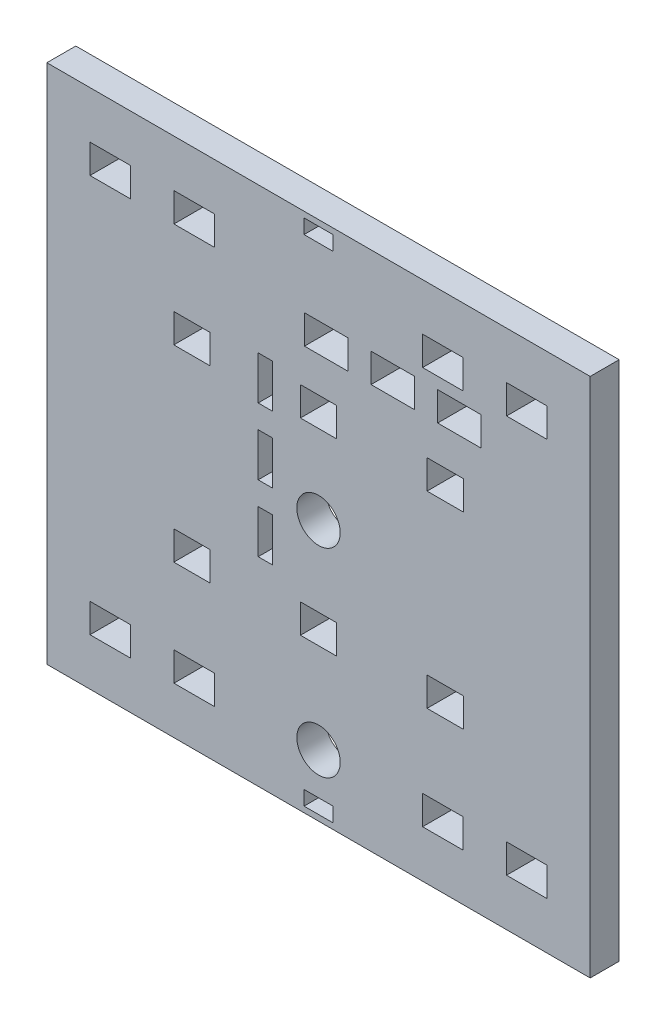
from build123d import *

# Parameters (mm, degrees)
SKETCH1_W           = 187.7087417
SKETCH1_H           = 180
SKETCH1_W_2         = 14
SKETCH1_H_2         = 10
SKETCH1_W_3         = 12.5
SKETCH1_W_4         = 5
SKETCH1_H_3         = 15
SKETCH1_W_5         = 10
SKETCH1_H_4         = 5
SKETCH1_R           = 7.5
SKETCH1_W_6         = 15
BOSS_EXTRUDE1_DEPTH = 10


with BuildPart() as part:
    # Sketch1 → Boss-Extrude1 (new body)
    with BuildSketch(Plane.XY):
        Rectangle(SKETCH1_W, SKETCH1_H)
        with Locations((-71.95437085, -68.7)):
            Rectangle(SKETCH1_W_2, SKETCH1_H_2, mode=Mode.SUBTRACT)
        with Locations((-42.95437085, -68.7)):
            Rectangle(SKETCH1_W_2, SKETCH1_H_2, mode=Mode.SUBTRACT)
        with Locations((-43.75, -32.5)):
            Rectangle(SKETCH1_W_3, SKETCH1_H_2, mode=Mode.SUBTRACT)
        with Locations((-18.35, -13.8)):
            Rectangle(SKETCH1_W_4, SKETCH1_H_3, mode=Mode.SUBTRACT)
        with Locations((0, -85.5)):
            Rectangle(SKETCH1_W_5, SKETCH1_H_4, mode=Mode.SUBTRACT)
        with Locations((0, -68.7)):
            Circle(SKETCH1_R, mode=Mode.SUBTRACT)
        with Locations((42.95437085, -68.7)):
            Rectangle(SKETCH1_W_2, SKETCH1_H_2, mode=Mode.SUBTRACT)
        with Locations((71.95437085, -68.7)):
            Rectangle(SKETCH1_W_2, SKETCH1_H_2, mode=Mode.SUBTRACT)
        with Locations((0, -32.5)):
            Rectangle(SKETCH1_W_3, SKETCH1_H_2, mode=Mode.SUBTRACT)
        with Locations((43.75, -32.5)):
            Rectangle(SKETCH1_W_3, SKETCH1_H_2, mode=Mode.SUBTRACT)
        Circle(SKETCH1_R, mode=Mode.SUBTRACT)
        with Locations((-18.35, 9.2)):
            Rectangle(SKETCH1_W_4, SKETCH1_H_3, mode=Mode.SUBTRACT)
        with Locations((-43.75, 32.5)):
            Rectangle(SKETCH1_W_3, SKETCH1_H_2, mode=Mode.SUBTRACT)
        with Locations((-18.35, 32.2)):
            Rectangle(SKETCH1_W_4, SKETCH1_H_3, mode=Mode.SUBTRACT)
        with Locations((-71.95437085, 68.7)):
            Rectangle(SKETCH1_W_2, SKETCH1_H_2, mode=Mode.SUBTRACT)
        with Locations((-42.95437085, 68.7)):
            Rectangle(SKETCH1_W_2, SKETCH1_H_2, mode=Mode.SUBTRACT)
        with Locations((0, 32.5)):
            Rectangle(SKETCH1_W_3, SKETCH1_H_2, mode=Mode.SUBTRACT)
        with Locations((43.75, 32.5)):
            Rectangle(SKETCH1_W_3, SKETCH1_H_2, mode=Mode.SUBTRACT)
        with Locations((2.65, 54.7)):
            Rectangle(SKETCH1_W_6, SKETCH1_H_2, mode=Mode.SUBTRACT)
        with Locations((25.65, 54.7)):
            Rectangle(SKETCH1_W_6, SKETCH1_H_2, mode=Mode.SUBTRACT)
        with Locations((0, 85.5)):
            Rectangle(SKETCH1_W_5, SKETCH1_H_4, mode=Mode.SUBTRACT)
        with Locations((42.95437085, 68.7)):
            Rectangle(SKETCH1_W_2, SKETCH1_H_2, mode=Mode.SUBTRACT)
        with Locations((48.65, 54.7)):
            Rectangle(SKETCH1_W_6, SKETCH1_H_2, mode=Mode.SUBTRACT)
        with Locations((71.95437085, 68.7)):
            Rectangle(SKETCH1_W_2, SKETCH1_H_2, mode=Mode.SUBTRACT)
    extrude(amount=BOSS_EXTRUDE1_DEPTH)


solid = part.part
